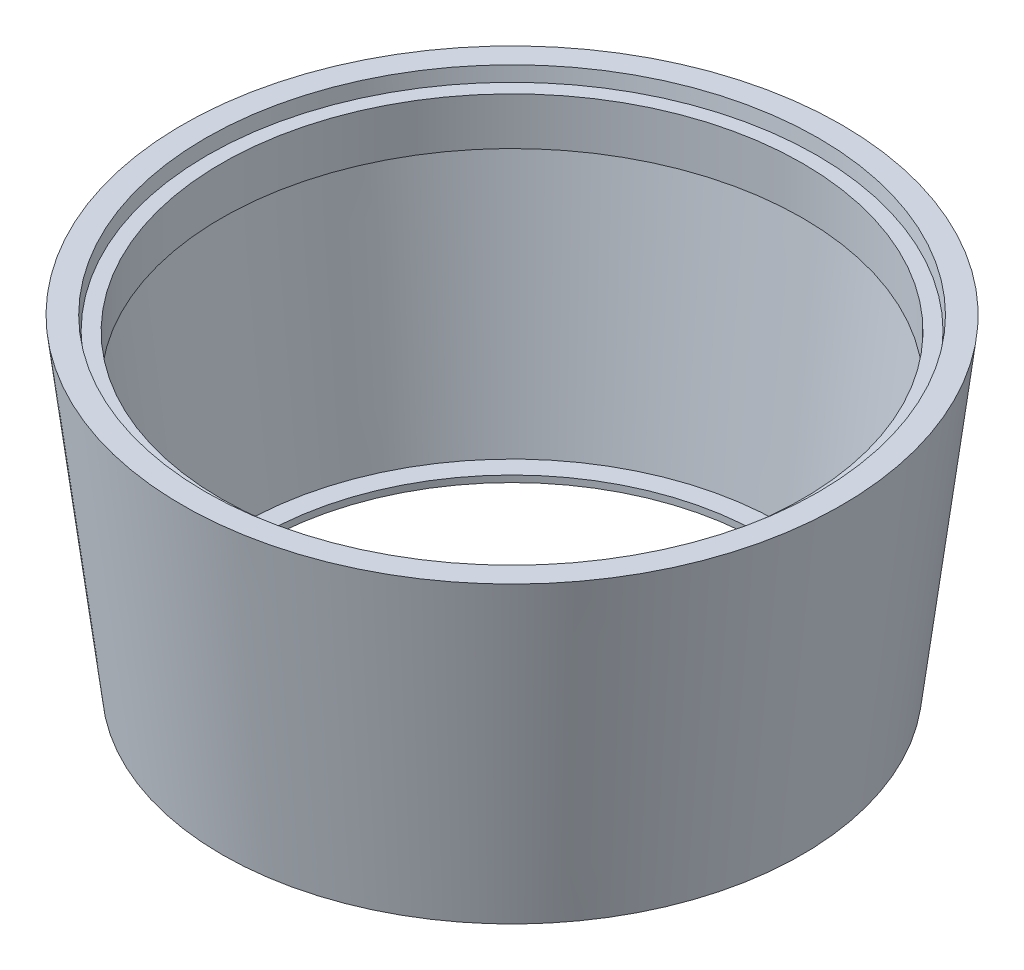
from build123d import *


with BuildPart() as part:
    # 草图1 → 旋转1 (revolve)
    with BuildSketch(Plane.XY):
        Polygon((-217.134859888, 0), (-133.260233749, 0), (-48.804778769, 687.834483087), (-98.098024954, 687.834483087), (-101.754105256, 658.058098538), (-131.977387408, 658.058098538), (-131.977387408, 557.028191998), (-108.829611217, 557.028191998), (-175.505089329, 14), (-217.134859888, 14), align=None)
    revolve(axis=Axis((-752, 0, 0), (0, 1, 0)))


solid = part.part
